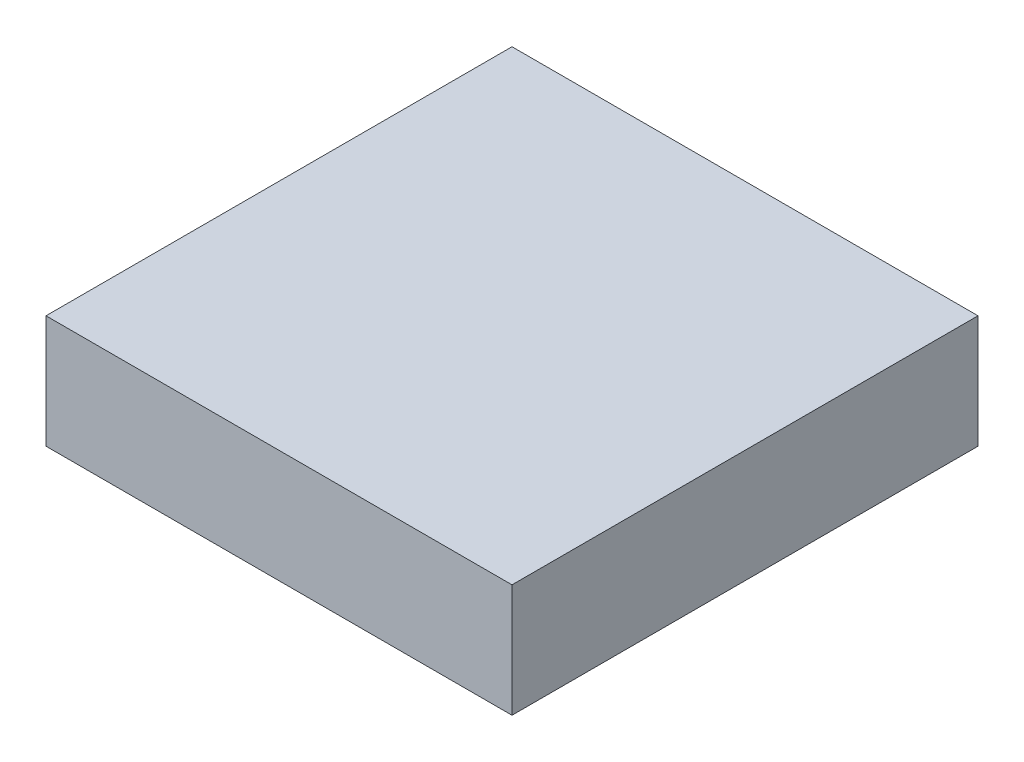
from build123d import *

# Parameters (mm, degrees)
SKETCH1_W           = 20.955
SKETCH1_H           = 20.955
BOSS_EXTRUDE1_DEPTH = 5.08


with BuildPart() as part:
    # Sketch1 → Boss-Extrude1 (new body)
    with BuildSketch(Plane(origin=(0, 0, 0), x_dir=(1, 0, 0), z_dir=(0, 1, 0))):
        Rectangle(SKETCH1_W, SKETCH1_H)
    extrude(amount=BOSS_EXTRUDE1_DEPTH)


solid = part.part
